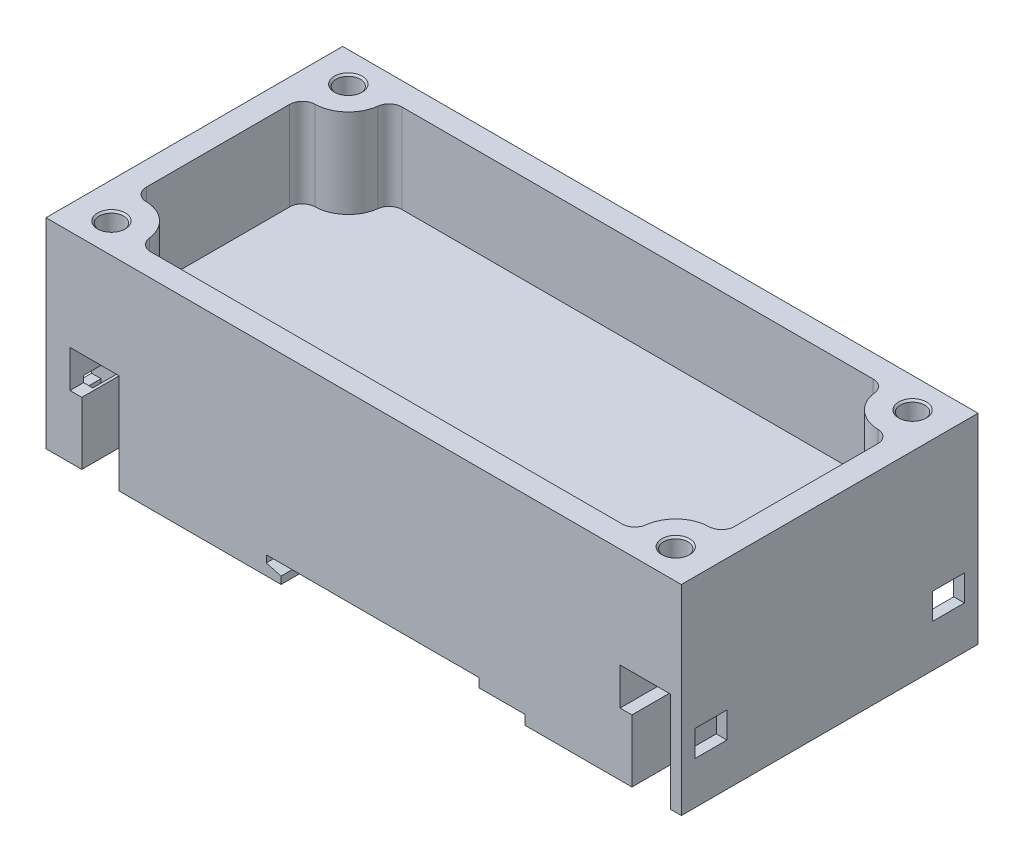
from build123d import *

# Parameters (mm, degrees)
BOSS_EXTRUDE1_DEPTH      = 25.05
BOSS_EXTRUDE1_DEPTH_BACK = 25.05
CUT_EXTRUDE1_DEPTH       = 15
SKETCH7_W                = 5.4
SKETCH7_H                = 4.4
CUT_EXTRUDE2_DEPTH       = 3
SKETCH8_W                = 5.4
SKETCH8_H                = 4.4
CUT_EXTRUDE3_DEPTH       = 3
SKETCH9_W                = 5.4
SKETCH9_H                = 4.4
CUT_EXTRUDE4_DEPTH       = 5
SKETCH10_W               = 5.4
SKETCH10_H               = 4.4
CUT_EXTRUDE5_DEPTH       = 5
SKETCH11_W               = 5.4
SKETCH11_H               = 5.4
CUT_EXTRUDE6_DEPTH       = 4
SKETCH12_W               = 5.4
SKETCH12_H               = 5.4
CUT_EXTRUDE7_DEPTH       = 4


with BuildPart() as part:
    # Sketch1 → Boss-Extrude1 (new, two sides: drawn at the far end of the back side and taken through both)
    with BuildSketch(Plane.XY.offset(-BOSS_EXTRUDE1_DEPTH_BACK)):
        Polygon((-53.65, 33.8), (-53.65, 0), (-47.6, 0), (-47.6, 10.55), (-49.6, 10.55), (-49.6, 16.85), (-41.3, 16.85), (-41.3, 0), (-13.95, 0), (-13.95, 1.230127019), (-16.45, 1.9), (-16.45, 3.1), (19.45, 3.1), (19.45, 1.6), (27.25, 1.6), (27.25, 0), (45.3, 0), (45.3, 10.55), (43.3, 10.55), (43.3, 16.85), (51.85, 16.85), (51.85, 0), (53.65, 0), (53.65, 33.8), align=None)
    extrude(amount=BOSS_EXTRUDE1_DEPTH + BOSS_EXTRUDE1_DEPTH_BACK)

    # Sketch2 → Cut-Revolve1 (revolve, cut)
    with BuildSketch(Plane.XY.offset(20)):
        with BuildLine():
            Line((47.65, 33.8), (50, 33.8))
            Line((50, 33.8), (49.7, 33.5))
            Line((49.7, 33.5), (49.7, 26.6))
            ThreePointArc((49.7, 26.6), (49.641421356, 26.458578644), (49.5, 26.4))
            Line((49.5, 26.4), (49.02, 26.4))
            Line((49.02, 26.4), (48.95, 18.4))
            Line((48.95, 18.4), (47.65, 18.4))
            Line((47.65, 18.4), (47.65, 33.8))
        make_face()
    revolve(axis=Axis((47.65, 18.4, 20), (0, 1, 0)), mode=Mode.SUBTRACT)

    # Sketch3 → Cut-Revolve2 (revolve, cut)
    with BuildSketch(Plane.XY.offset(-20)):
        with BuildLine():
            Line((47.65, 33.8), (50, 33.8))
            Line((50, 33.8), (49.7, 33.5))
            Line((49.7, 33.5), (49.7, 26.6))
            ThreePointArc((49.7, 26.6), (49.641421356, 26.458578644), (49.5, 26.4))
            Line((49.5, 26.4), (49.02, 26.4))
            Line((49.02, 26.4), (48.95, 18.4))
            Line((48.95, 18.4), (47.65, 18.4))
            Line((47.65, 18.4), (47.65, 33.8))
        make_face()
    revolve(axis=Axis((47.65, 18.4, -20), (0, 1, 0)), mode=Mode.SUBTRACT)

    # Sketch4 → Cut-Revolve3 (revolve, cut)
    with BuildSketch(Plane.XY.offset(-20)):
        with BuildLine():
            Line((-47.65, 33.8), (-45.3, 33.8))
            Line((-45.3, 33.8), (-45.6, 33.5))
            Line((-45.6, 33.5), (-45.6, 26.6))
            ThreePointArc((-45.6, 26.6), (-45.658578644, 26.458578644), (-45.8, 26.4))
            Line((-45.8, 26.4), (-46.28, 26.4))
            Line((-46.28, 26.4), (-46.35, 18.4))
            Line((-46.35, 18.4), (-47.65, 18.4))
            Line((-47.65, 18.4), (-47.65, 33.8))
        make_face()
    revolve(axis=Axis((-47.65, 18.4, -20), (0, 1, 0)), mode=Mode.SUBTRACT)

    # Sketch5 → Cut-Revolve4 (revolve, cut)
    with BuildSketch(Plane.XY.offset(20)):
        with BuildLine():
            Line((-47.65, 33.8), (-45.3, 33.8))
            Line((-45.3, 33.8), (-45.6, 33.5))
            Line((-45.6, 33.5), (-45.6, 26.6))
            ThreePointArc((-45.6, 26.6), (-45.658578644, 26.458578644), (-45.8, 26.4))
            Line((-45.8, 26.4), (-46.28, 26.4))
            Line((-46.28, 26.4), (-46.35, 18.4))
            Line((-46.35, 18.4), (-47.65, 18.4))
            Line((-47.65, 18.4), (-47.65, 33.8))
        make_face()
    revolve(axis=Axis((-47.65, 18.4, 20), (0, 1, 0)), mode=Mode.SUBTRACT)

    # Sketch6 → Cut-Extrude1 (cut)
    with BuildSketch(Plane(origin=(0, 33.8, 0), x_dir=(1, 0, 0), z_dir=(0, 1, 0))):
        with BuildLine():
            Line((-39.807328261, -21.2), (39.807328261, -21.2))
            ThreePointArc((39.807328261, -21.2), (41.233271764, -20.659094505), (41.941726266, -19.308544304))
            ThreePointArc((41.941726266, -19.308544304), (43.795745244, -15.733008053), (47.540822869, -14.251036584))
            ThreePointArc((47.540822869, -14.251036584), (49.034644775, -13.607201525), (49.65, -12.101424179))
            Line((49.65, -12.101424179), (49.65, 12.101424179))
            ThreePointArc((49.65, 12.101424179), (49.034644745, 13.607201555), (47.540822785, 14.251036586))
            ThreePointArc((47.540822785, 14.251036586), (43.795745267, 15.733008032), (41.941726284, 19.308544159))
            ThreePointArc((41.941726284, 19.308544159), (41.233271819, 20.659094457), (39.807328261, 21.2))
            Line((39.807328261, 21.2), (-39.807328261, 21.2))
            ThreePointArc((-39.807328261, 21.2), (-41.233271718, 20.659094546), (-41.941726251, 19.308544426))
            ThreePointArc((-41.941726251, 19.308544426), (-43.795745113, 15.733008171), (-47.540822639, 14.251036589))
            ThreePointArc((-47.540822639, 14.251036589), (-49.034644694, 13.607201607), (-49.65, 12.101424179))
            Line((-49.65, 12.101424179), (-49.65, -12.101424179))
            ThreePointArc((-49.65, -12.101424179), (-49.034644783, -13.607201517), (-47.540822892, -14.251036584))
            ThreePointArc((-47.540822892, -14.251036584), (-43.795745253, -15.733008045), (-41.941726266, -19.308544304))
            ThreePointArc((-41.941726266, -19.308544304), (-41.233271764, -20.659094505), (-39.807328261, -21.2))
        make_face()
    extrude(amount=-CUT_EXTRUDE1_DEPTH, mode=Mode.SUBTRACT)

    # Sketch7 → Cut-Extrude2 (cut)
    with BuildSketch(Plane(origin=(53.65, 0, 0), x_dir=(0, 0, -1), z_dir=(1, 0, 0))):
        with Locations((20.05, 9.4)):
            Rectangle(SKETCH7_W, SKETCH7_H)
    extrude(amount=-CUT_EXTRUDE2_DEPTH, mode=Mode.SUBTRACT)

    # Sketch8 → Cut-Extrude3 (cut)
    with BuildSketch(Plane(origin=(53.65, 0, 0), x_dir=(0, 0, -1), z_dir=(1, 0, 0))):
        with Locations((-20.05, 9.4)):
            Rectangle(SKETCH8_W, SKETCH8_H)
    extrude(amount=-CUT_EXTRUDE3_DEPTH, mode=Mode.SUBTRACT)

    # Sketch9 → Cut-Extrude4 (cut)
    with BuildSketch(Plane(origin=(-53.65, 0, 0), x_dir=(0, 0, -1), z_dir=(1, 0, 0))):
        with Locations((20.05, 9.4)):
            Rectangle(SKETCH9_W, SKETCH9_H)
    extrude(amount=CUT_EXTRUDE4_DEPTH, mode=Mode.SUBTRACT)

    # Sketch10 → Cut-Extrude5 (cut)
    with BuildSketch(Plane(origin=(-53.65, 0, 0), x_dir=(0, 0, -1), z_dir=(1, 0, 0))):
        with Locations((-20.05, 9.4)):
            Rectangle(SKETCH10_W, SKETCH10_H)
    extrude(amount=CUT_EXTRUDE5_DEPTH, mode=Mode.SUBTRACT)

    # Sketch11 → Cut-Extrude6 (cut)
    with BuildSketch(Plane(origin=(-52.05, 0, 0), x_dir=(0, 0, -1), z_dir=(1, 0, 0))):
        with Locations((-20.05, 8.9)):
            Rectangle(SKETCH11_W, SKETCH11_H)
    extrude(amount=CUT_EXTRUDE6_DEPTH, mode=Mode.SUBTRACT)

    # Sketch12 → Cut-Extrude7 (cut)
    with BuildSketch(Plane(origin=(-52.05, 0, 0), x_dir=(0, 0, -1), z_dir=(1, 0, 0))):
        with Locations((20.05, 8.9)):
            Rectangle(SKETCH12_W, SKETCH12_H)
    extrude(amount=CUT_EXTRUDE7_DEPTH, mode=Mode.SUBTRACT)


solid = part.part
